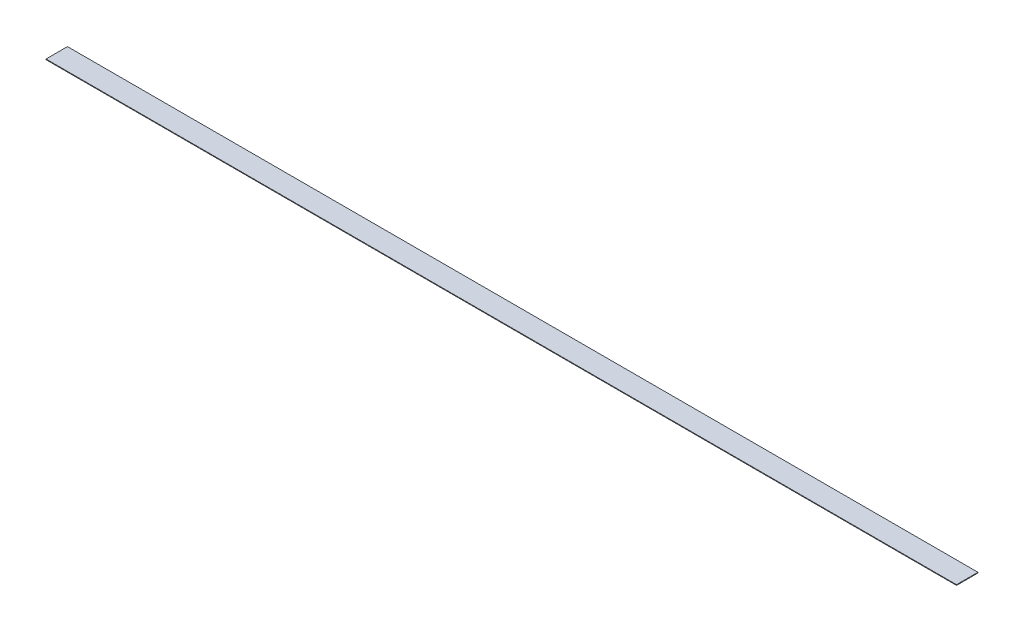
from build123d import *

# Parameters (mm, degrees)
SKETCH1_W           = 673.1
SKETCH1_H           = 15.875
BOSS_EXTRUDE1_DEPTH = 0.4572


with BuildPart() as part:
    # Sketch1 → Boss-Extrude1 (new body)
    with BuildSketch(Plane(origin=(0, 0, 0), x_dir=(1, 0, 0), z_dir=(0, 1, 0))):
        Rectangle(SKETCH1_W, SKETCH1_H)
    extrude(amount=BOSS_EXTRUDE1_DEPTH)


solid = part.part
